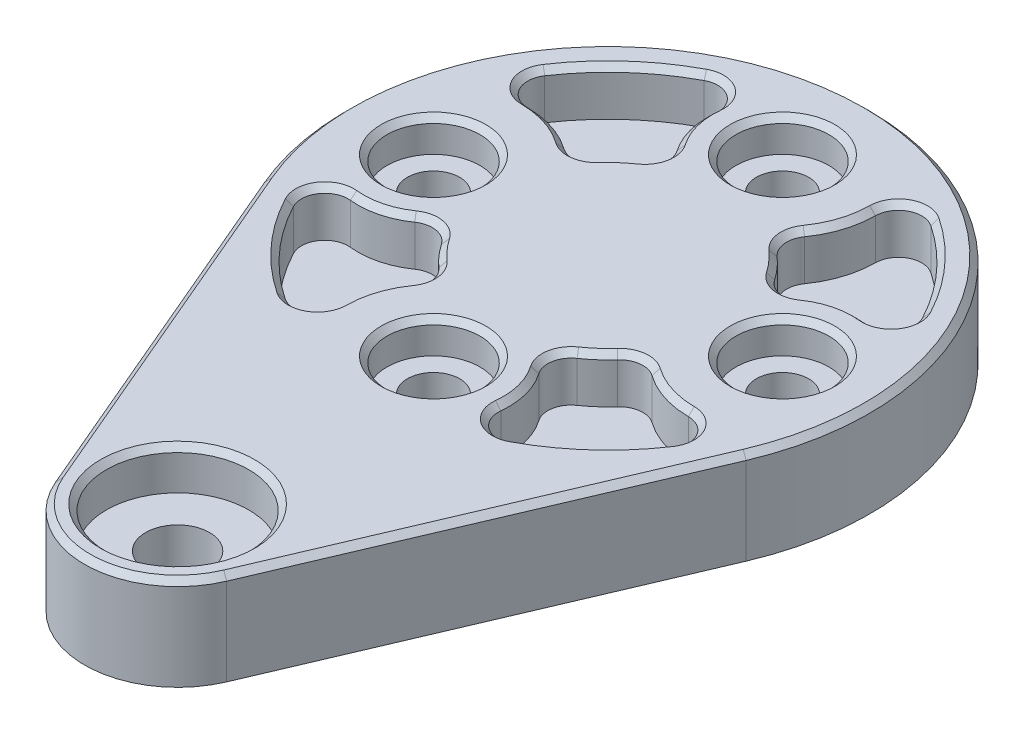
from build123d import *

# Parameters (mm, degrees)
SKETCH1_R                                    = 8
SKETCH1_R_2                                  = 22.5
BOSS_EXTRUDE1_DEPTH                          = 8
CBORE_FOR_M4_HEX_HEAD_CAP_SCREW1_D           = 4.5
CBORE_FOR_M4_HEX_HEAD_CAP_SCREW1_CBORE_D     = 8
CBORE_FOR_M4_HEX_HEAD_CAP_SCREW1_CBORE_DEPTH = 2.8
CBORE_FOR_M5_HEX_HEAD_CAP_SCREW1_D           = 5.5
CBORE_FOR_M5_HEX_HEAD_CAP_SCREW1_CBORE_D     = 12.238
CBORE_FOR_M5_HEX_HEAD_CAP_SCREW1_CBORE_DEPTH = 3.5
CUT_EXTRUDE1_DEPTH                           = 4
FILLET1_R                                    = 2
CIRPATTERN1_COUNT                            = 4
FILLET1_OF_CIRPATTERN1_R                     = 2
CHAMFER1_SIZE                                = 0.5


with BuildPart() as part:
    # Sketch1 → Boss-Extrude1 (new body)
    with BuildSketch(Plane(origin=(0, 0, 0), x_dir=(0, 0, -1), z_dir=(0, 1, 0))):
        with BuildLine():
            Line((28.182432432, 20.700253675), (-3.135135135, 7.360090195))
            ThreePointArc((-3.135135135, 7.360090195), (4.411287733, 6.673869982), (8, 0))
            ThreePointArc((8, 0), (4.411287733, -6.673869982), (-3.135135135, -7.360090195))
            Line((-3.135135135, -7.360090195), (28.182432432, -20.700253675))
            ThreePointArc((28.182432432, -20.700253675), (14.5, 0), (28.182432432, 20.700253675))
        make_face()
        Circle(SKETCH1_R)
        with Locations((37, 0)):
            Circle(SKETCH1_R_2)
    extrude(amount=BOSS_EXTRUDE1_DEPTH)

    # CBORE for M4 Hex Head Cap Screw1 (through all)
    with Locations(Plane(origin=(0, 8, 0), x_dir=(0, 0, -1), z_dir=(0, 1, 0))):
        with Locations((37, 15), (52, 0), (37, -15), (22, 0)):
            CounterBoreHole(CBORE_FOR_M4_HEX_HEAD_CAP_SCREW1_D / 2, CBORE_FOR_M4_HEX_HEAD_CAP_SCREW1_CBORE_D / 2, CBORE_FOR_M4_HEX_HEAD_CAP_SCREW1_CBORE_DEPTH)

    # CBORE for M5 Hex Head Cap Screw1 (through all)
    with Locations(Plane(origin=(0, 8, 0), x_dir=(0, 0, -1), z_dir=(0, 1, 0))):
        with Locations((0, 0)):
            CounterBoreHole(CBORE_FOR_M5_HEX_HEAD_CAP_SCREW1_D / 2, CBORE_FOR_M5_HEX_HEAD_CAP_SCREW1_CBORE_D / 2, CBORE_FOR_M5_HEX_HEAD_CAP_SCREW1_CBORE_DEPTH)

    # Sketch9 → Cut-Extrude1 (cut)
    with BuildSketch(Plane(origin=(0, 8, 0), x_dir=(0, 0, -1), z_dir=(0, 1, 0))):
        with BuildLine():
            ThreePointArc((32.238763291, 19.425), (30.540814877, 14.272725949), (33.341968933, 9.627029805))
            ThreePointArc((33.341968933, 9.627029805), (30.354454664, 7.867504137), (28.120160936, 5.216258464))
            ThreePointArc((28.120160936, 5.216258464), (23.557965092, 7.889136012), (18.322190742, 7.151184609))
            ThreePointArc((18.322190742, 7.151184609), (23.77090876, 14.999704829), (32.238763291, 19.425))
        make_face()
    cut_extrude1 = extrude(amount=-CUT_EXTRUDE1_DEPTH, mode=Mode.SUBTRACT)

    # Fillet1
    fillet1_edges = [part.edges().sort_by_distance(p)[0] for p in [
        (-7.151184609, 6, -18.322190742),
        (-19.425, 6, -32.238763291),
        (-9.627029805, 6, -33.341968933),
        (-5.216258464, 6, -28.120160936),
    ]]
    fillet(fillet1_edges, radius=FILLET1_R)

    # CirPattern1: Cut-Extrude1 ×4 about axis
    cirpattern1_axis = Axis((0, 0, -37), (0, 1, 0))
    for i in range(1, CIRPATTERN1_COUNT):
        add(cut_extrude1.rotate(cirpattern1_axis, i * 360 / CIRPATTERN1_COUNT), mode=Mode.SUBTRACT)

    # Fillet1 of CirPattern1
    fillet1_of_cirpattern1_edges = [part.edges().sort_by_distance(p)[0] for p in [
        (18.677809258, 6, -29.848815391),
        (4.761236709, 6, -17.575),
        (3.658031067, 6, -27.372970195),
        (8.879839064, 6, -31.783741536),
        (7.151184609, 6, -55.677809258),
        (19.425, 6, -41.761236709),
        (9.627029805, 6, -40.658031067),
        (5.216258464, 6, -45.879839064),
        (-18.677809258, 6, -44.151184609),
        (-4.761236709, 6, -56.425),
        (-3.658031067, 6, -46.627029805),
        (-8.879839064, 6, -42.216258464),
    ]]
    fillet(fillet1_of_cirpattern1_edges, radius=FILLET1_OF_CIRPATTERN1_R)

    # Chamfer1
    chamfer1_edges = [part.edges().sort_by_distance(p)[0] for p in [
        (0, 8, -59.5),
        (6.810875883, 8, -29.275178717),
        (12.530733125, 8, -29.346997756),
        (6.294303696, 8, -23.622264153),
        (13.39585301, 8, -22.149036323),
        (8.956618689, 8, -30.803972614),
        (5.001114467, 8, -27.223343635),
        (7.33454102, 8, -19.450376243),
        (16.706928422, 8, -27.893686221),
        (-14.030171935, 8, -12.523648649),
        (7.724821283, 8, -43.810875883),
        (7.653002244, 8, -49.530733125),
        (13.377735847, 8, -43.294303696),
        (14.850963677, 8, -50.39585301),
        (6.196027386, 8, -45.956618689),
        (9.776656365, 8, -42.001114467),
        (17.549623757, 8, -44.33454102),
        (9.106313781, 8, -53.706928418),
        (-6.810875883, 8, -44.724821283),
        (-12.530733125, 8, -44.653002244),
        (-6.294303696, 8, -50.377735847),
        (-13.39585301, 8, -51.850963677),
        (0, 8, -18),
        (-8.956618689, 8, -43.196027386),
        (-5.001114467, 8, -46.776656365),
        (-7.334541019, 8, -54.549623756),
        (-16.706928422, 8, -46.106313779),
        (0, 8, 8),
        (15, 8, -33),
        (0, 8, -48),
        (-15, 8, -33),
        (0, 8, 6.119),
        (14.030171935, 8, -12.523648649),
        (-7.724821283, 8, -30.189124117),
        (-7.653002244, 8, -24.469266875),
        (-13.377735847, 8, -30.705696304),
        (-14.850963677, 8, -23.60414699),
        (-6.196027386, 8, -28.043381311),
        (-9.776656365, 8, -31.998885533),
        (-17.549623757, 8, -29.66545898),
        (-9.106313779, 8, -20.293071578),
    ]]
    chamfer(chamfer1_edges, length=CHAMFER1_SIZE)


solid = part.part
